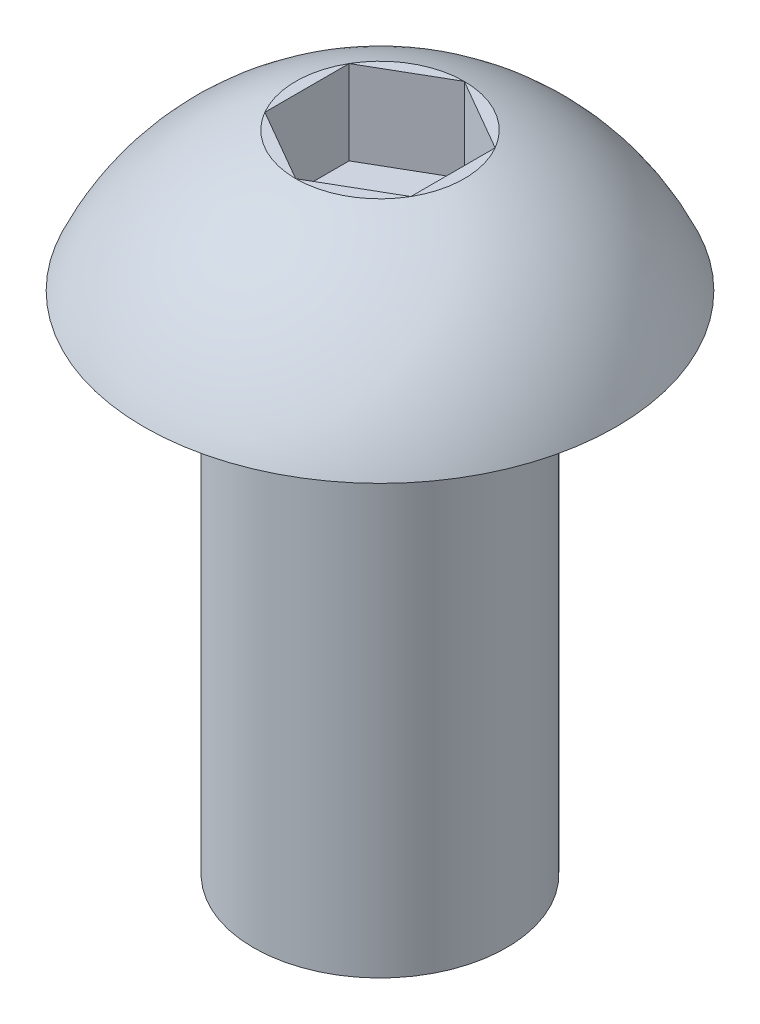
from build123d import *

# Parameters (mm, degrees)
SKETCH2_R           = 1.5
BOSS_EXTRUDE1_DEPTH = 6
CUT_EXTRUDE1_DEPTH  = 1


with BuildPart() as part:
    # Sketch1 → Revolve1 (revolve)
    with BuildSketch(Plane(origin=(0, 0, 0), x_dir=(0, 0, -1), z_dir=(1, 0, 0))):
        with BuildLine():
            Line((0, 0), (0, 1.65))
            Line((0, 1.65), (-1, 1.65))
            ThreePointArc((-1, 1.65), (-2.075469546, 1.016421323), (-2.8, 0))
            Line((-2.8, 0), (0, 0))
        make_face()
    revolve(axis=Axis((0, 4.725289413, 0), (0, -1, 0)))

    # Sketch2 → Boss-Extrude1 (add)
    with BuildSketch(Plane.XZ):
        Circle(SKETCH2_R)
    extrude(amount=BOSS_EXTRUDE1_DEPTH)

    # Sketch3 → Cut-Extrude1 (cut)
    with BuildSketch(Plane(origin=(0, 1.65, 0), x_dir=(1, 0, 0), z_dir=(0, 1, 0))):
        Polygon((0, 1), (-0.866025404, 0.5), (-0.866025404, -0.5), (0, -1), (0.866025404, -0.5), (0.866025404, 0.5), align=None)
    extrude(amount=-CUT_EXTRUDE1_DEPTH, mode=Mode.SUBTRACT)


solid = part.part
